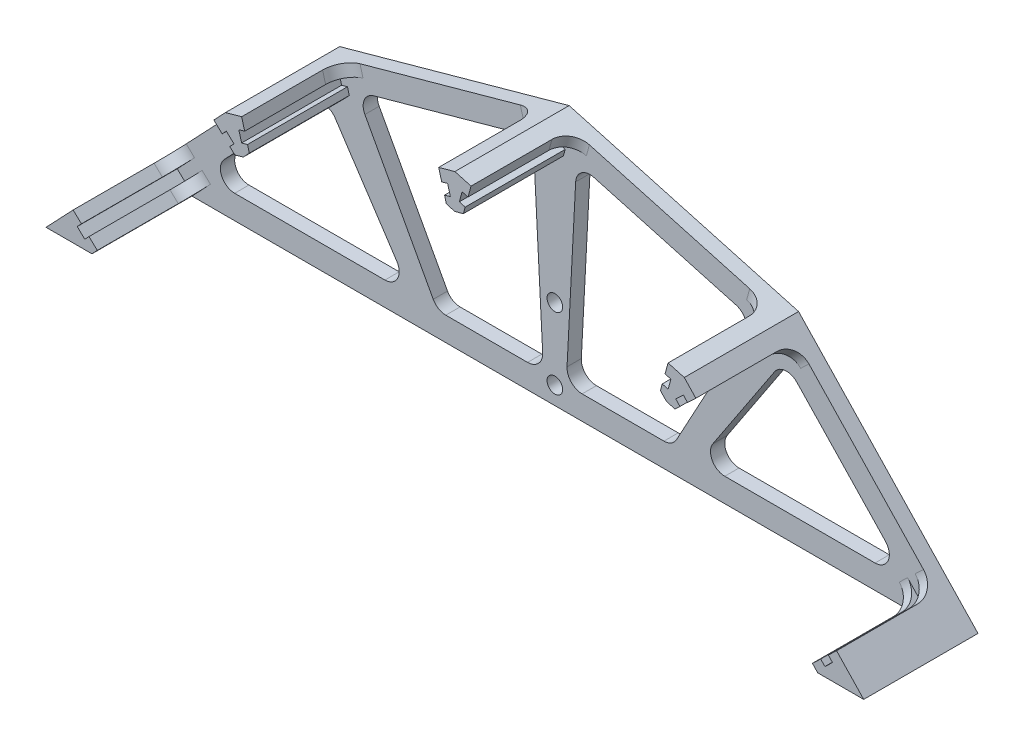
from build123d import *

# Parameters (mm, degrees)
BOSS_EXTRUDE1_DEPTH = 3
BOSS_EXTRUDE2_DEPTH = 21
SKETCH3_R           = 1.642484664
CUT_EXTRUDE1_DEPTH  = 101.008681907
FILLET3_R           = 4
FILLET4_R           = 4


with BuildPart() as part:
    # Sketch1 → Boss-Extrude1 (new body)
    with BuildSketch(Plane.XY):
        Polygon((0, 46.774719198), (48.18152266, 33.412800394), (82.599251445, -2.855918156), (85.865371953, -6.297691035), (78.97237959, -6.297691035), (-78.97237959, -6.297691035), (-85.865371953, -6.297691035), (-82.599251445, -2.855918156), (-48.18152266, 33.412800394), align=None)
    extrude(amount=BOSS_EXTRUDE1_DEPTH)

    # Sketch2 → Boss-Extrude2 (add)
    with BuildSketch(Plane.XY.offset(3)):
        Polygon((-44.779907161, 34.356151862), (-48.18152266, 33.412800394), (-50.611414313, 30.852228864), (-48.870515822, 29.200177883), (-47.989421965, 30.128657078), (-46.393598349, 28.614277011), (-47.274692206, 27.685797816), (-46.22623914, 26.690853007), (-44.440185395, 27.186169547), (-43.164345406, 28.530624372), (-43.550610631, 29.923451777), (-44.784057611, 29.581386656), (-45.371982038, 31.701373653), (-44.138535058, 32.043438774), align=None)
        Polygon((0, 46.774719198), (-3.4016155, 45.83136773), (-2.760243397, 43.518654643), (-1.526796417, 43.860719764), (-0.93887199, 41.740732767), (-2.17231897, 41.398667646), (-1.786053745, 40.00584024), (0, 39.5105237), (1.786053745, 40.00584024), (2.17231897, 41.398667646), (0.93887199, 41.740732767), (1.526796417, 43.860719764), (2.760243397, 43.518654643), (3.4016155, 45.83136773), align=None)
        Polygon((-78.428461302, -1.947397608), (-80.169359793, -0.295346627), (-85.865371953, -6.297691035), (-76.215182645, -6.297691035), (-75.091739196, -5.113828657), (-76.832637686, -3.461777675), (-77.713731543, -4.39025687), (-79.309555159, -2.875876803), align=None)
        Polygon((48.18152266, 33.412800394), (44.779907161, 34.356151862), (44.138535058, 32.043438774), (45.371982038, 31.701373653), (44.784057611, 29.581386656), (43.550610631, 29.923451777), (43.164345406, 28.530624372), (44.440185395, 27.186169547), (46.22623914, 26.690853007), (47.274692206, 27.685797816), (46.393598349, 28.614277011), (47.989421965, 30.128657078), (48.870515822, 29.200177883), (50.611414313, 30.852228864), align=None)
        Polygon((75.091739196, -5.113828657), (76.215182645, -6.297691035), (85.865371953, -6.297691035), (80.169359793, -0.295346627), (78.428461302, -1.947397608), (79.309555159, -2.875876803), (77.713731543, -4.39025687), (76.832637686, -3.461777675), align=None)
    extrude(amount=BOSS_EXTRUDE2_DEPTH)

    # Sketch3 → Cut-Extrude1 (cut, through all)
    with BuildSketch(Plane.XY.offset(3)):
        with Locations((0, -2.554468846)):
            Circle(SKETCH3_R)
        with Locations((0, 12.445531154)):
            Circle(SKETCH3_R)
        with BuildLine():
            Line((-69.420990751, 3.767372692), (-50.828151114, 23.360137575))
            ThreePointArc((-50.828151114, 23.360137575), (-48.390560772, 24.283657942), (-46.150370534, 22.950884804))
            Line((-46.150370534, 22.950884804), (-33.182202355, 3.358119921))
            ThreePointArc((-33.182202355, 3.358119921), (-33.041187606, 0.282349963), (-35.683859821, -1.297691035))
            Line((-35.683859821, -1.297691035), (-67.244867638, -1.297691035))
            ThreePointArc((-67.244867638, -1.297691035), (-70.001241269, 0.518077396), (-69.420990751, 3.767372692))
        make_face()
        with BuildLine():
            Line((-25.543650537, 0.270832684), (-39.897767636, 26.707827652))
            ThreePointArc((-39.897767636, 26.707827652), (-40.022830858, 29.311497318), (-38.063031426, 31.030195292))
            Line((-38.063031426, 31.030195292), (-8.166425929, 39.321257781))
            ThreePointArc((-8.166425929, 39.321257781), (-5.611961803, 38.865088367), (-4.368822196, 36.58737429))
            Line((-4.368822196, 36.58737429), (-2.558453179, 2.043475626))
            ThreePointArc((-2.558453179, 2.043475626), (-3.426038324, -0.308216813), (-5.729101952, -1.297691035))
            Line((-5.729101952, -1.297691035), (-22.907199199, -1.297691035))
            ThreePointArc((-22.907199199, -1.297691035), (-24.441078457, -0.875910269), (-25.543650537, 0.270832684))
        make_face()
        with BuildLine():
            Line((5.729101952, -1.297691035), (22.907199199, -1.297691035))
            ThreePointArc((22.907199199, -1.297691035), (24.441078457, -0.875910269), (25.543650537, 0.270832684))
            Line((25.543650537, 0.270832684), (39.897767636, 26.707827652))
            ThreePointArc((39.897767636, 26.707827652), (40.022830858, 29.311497318), (38.063031426, 31.030195292))
            Line((38.063031426, 31.030195292), (8.166425929, 39.321257781))
            ThreePointArc((8.166425929, 39.321257781), (5.611961803, 38.865088367), (4.368822196, 36.58737429))
            Line((4.368822196, 36.58737429), (2.558453179, 2.043475626))
            ThreePointArc((2.558453179, 2.043475626), (3.426038324, -0.308216813), (5.729101952, -1.297691035))
        make_face()
        with BuildLine():
            Line((35.683859821, -1.297691035), (67.244867638, -1.297691035))
            ThreePointArc((67.244867638, -1.297691035), (70.001241269, 0.518077396), (69.420990751, 3.767372692))
            Line((69.420990751, 3.767372692), (50.828151114, 23.360137575))
            ThreePointArc((50.828151114, 23.360137575), (48.390560772, 24.283657942), (46.150370534, 22.950884804))
            Line((46.150370534, 22.950884804), (33.182202355, 3.358119921))
            ThreePointArc((33.182202355, 3.358119921), (33.041187606, 0.282349963), (35.683859821, -1.297691035))
        make_face()
    extrude(amount=-CUT_EXTRUDE1_DEPTH, mode=Mode.SUBTRACT)

    # Fillet3
    fillet3_edges = [part.edges().sort_by_distance(p)[0] for p in [
        (-79.298910548, -1.121372118, 3),
    ]]
    fillet(fillet3_edges, radius=FILLET3_R)

    # Fillet4
    fillet4_edges = [part.edges().sort_by_distance(p)[0] for p in [
        (79.298910548, -1.121372118, 3),
        (49.740965067, 30.026203374, 3),
        (44.459221109, 33.199795318, 3),
        (3.080929449, 44.675011187, 3),
        (-3.080929449, 44.675011187, 3),
        (-44.459221109, 33.199795318, 3),
        (-75.962188441, -4.287803166, 3),
        (-49.740965067, 30.026203374, 3),
        (75.962188441, -4.287803166, 3),
    ]]
    fillet(fillet4_edges, radius=FILLET4_R)


solid = part.part
